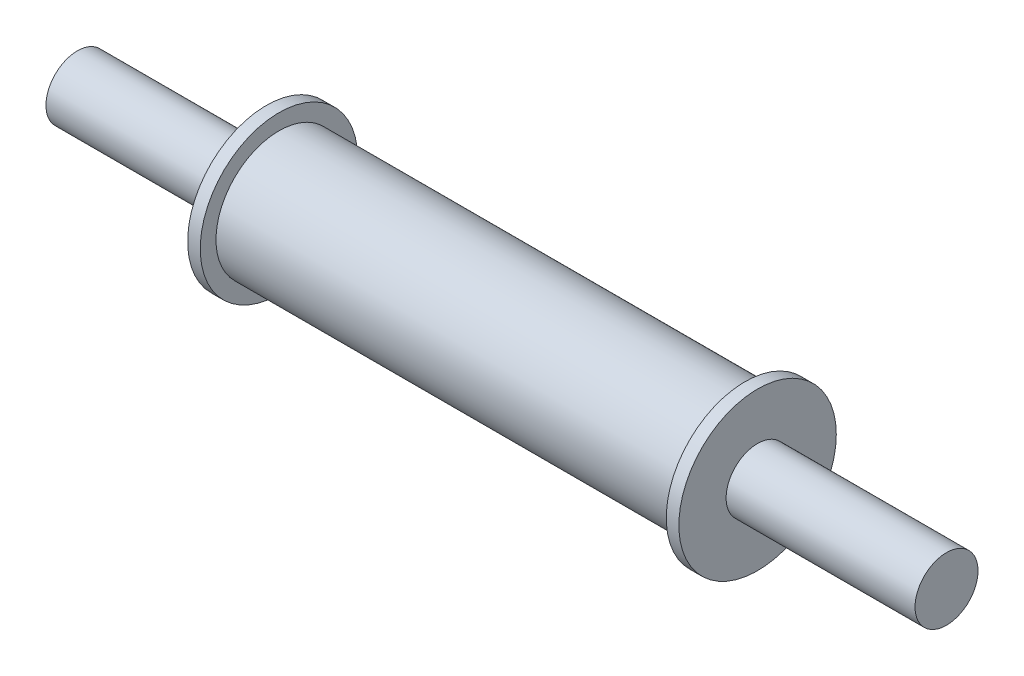
from build123d import *

# Parameters (mm, degrees)
SKETCH1_R           = 10
BOSS_EXTRUDE1_DEPTH = 37
SKETCH2_R           = 12.5
BOSS_EXTRUDE2_DEPTH = 2
SKETCH3_R           = 5
BOSS_EXTRUDE3_DEPTH = 30


with BuildPart() as part:
    # Sketch1 → Boss-Extrude1 (new body)
    with BuildSketch(Plane(origin=(0, 0, 0), x_dir=(0, 0, -1), z_dir=(1, 0, 0))):
        Circle(SKETCH1_R)
    boss_extrude1 = extrude(amount=BOSS_EXTRUDE1_DEPTH)

    # Sketch2 → Boss-Extrude2 (add)
    with BuildSketch(Plane(origin=(37, 0, 0), x_dir=(0, 0, -1), z_dir=(1, 0, 0))):
        Circle(SKETCH2_R)
    boss_extrude2 = extrude(amount=BOSS_EXTRUDE2_DEPTH)

    # Sketch3 → Boss-Extrude3 (add)
    with BuildSketch(Plane(origin=(39, 0, 0), x_dir=(0, 0, -1), z_dir=(1, 0, 0))):
        Circle(SKETCH3_R)
    boss_extrude3 = extrude(amount=BOSS_EXTRUDE3_DEPTH)

    # Mirror2: Boss-Extrude1, Boss-Extrude2, Boss-Extrude3 across plane
    add(boss_extrude1.mirror(Plane(origin=(0, 0, 0), x_dir=(0, 0, 1), z_dir=(1, 0, 0))))
    add(boss_extrude2.mirror(Plane(origin=(0, 0, 0), x_dir=(0, 0, 1), z_dir=(1, 0, 0))))
    add(boss_extrude3.mirror(Plane(origin=(0, 0, 0), x_dir=(0, 0, 1), z_dir=(1, 0, 0))))


solid = part.part
